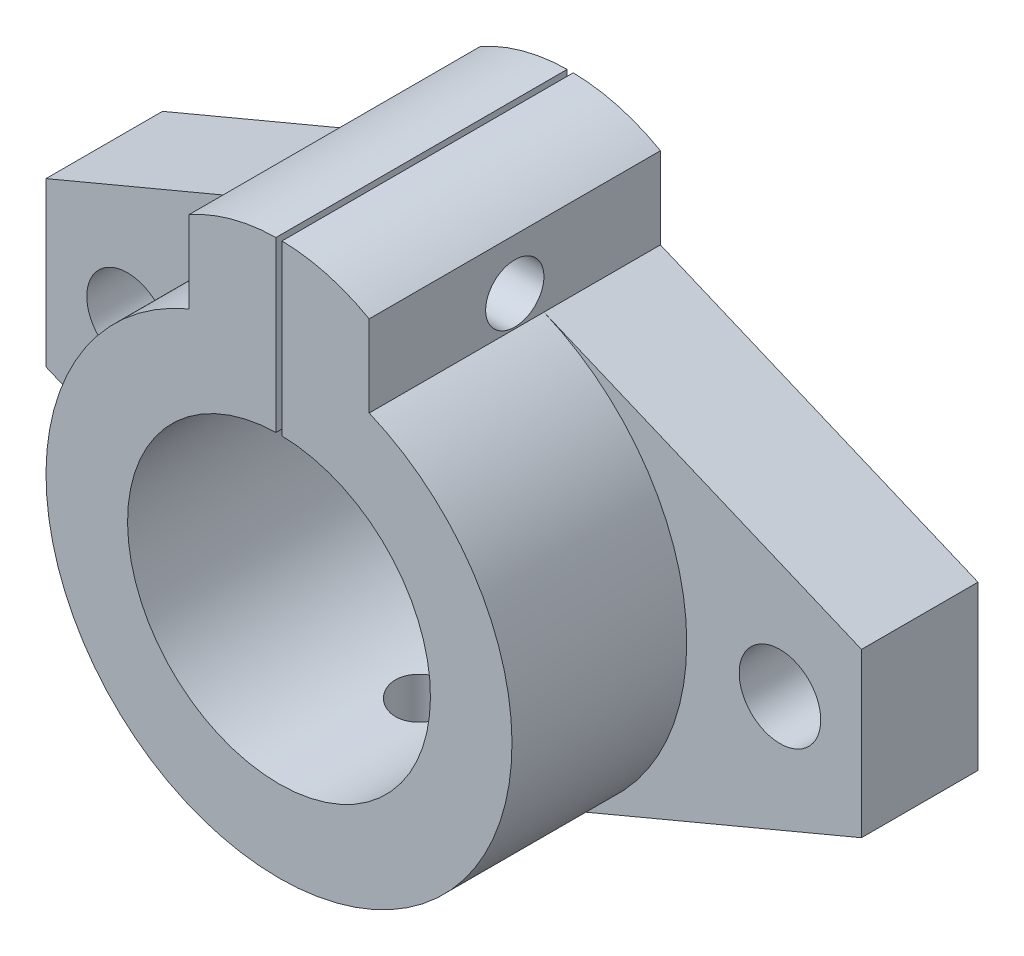
from build123d import *

# Parameters (mm, degrees)
SKETCH_1_R          = 3.5
SKETCH_1_R_2        = 13
EXTRUDE_2_DEPTH     = 10
SKETCH_2_R          = 13
EXTRUDE_3_DEPTH     = 15
SKETCH_3_W          = 0.517195108
SKETCH_3_H          = 18.726193104
CUT_EXTRUDE_1_DEPTH = 26
SKETCH_4_R          = 2.5
CUT_EXTRUDE_2_DEPTH = 43.740275714
SKETCH_5_R          = 2.5
CUT_EXTRUDE_3_DEPTH = 21


with BuildPart() as part:
    # 草图1 → 凸台-拉伸2 (new body)
    with BuildSketch(Plane.XY):
        with BuildLine():
            Line((-35, -7), (-7.740275714, -18.44147857))
            ThreePointArc((-7.740275714, -18.44147857), (0, -20), (7.740275714, -18.44147857))
            Line((7.740275714, -18.44147857), (35, -7))
            Line((35, -7), (35, 7))
            Line((35, 7), (7.740275714, 18.44147857))
            Line((7.740275714, 18.44147857), (7.740275714, 25.44147857))
            ThreePointArc((7.740275714, 25.44147857), (0, 27.494244152), (-7.740275714, 25.44147857))
            Line((-7.740275714, 25.44147857), (-7.740275714, 18.44147857))
            Line((-7.740275714, 18.44147857), (-35, 7))
            Line((-35, 7), (-35, -7))
        make_face()
        with Locations((-28, 0)):
            Circle(SKETCH_1_R, mode=Mode.SUBTRACT)
        Circle(SKETCH_1_R_2, mode=Mode.SUBTRACT)
        with Locations((28, 0)):
            Circle(SKETCH_1_R, mode=Mode.SUBTRACT)
    extrude(amount=EXTRUDE_2_DEPTH)

    # 草图2 → 凸台-拉伸3 (add)
    with BuildSketch(Plane.XY.offset(10)):
        with BuildLine():
            Line((-7.740275714, 18.44147857), (-7.740275714, 25.44147857))
            ThreePointArc((-7.740275714, 25.44147857), (0, 27.494244152), (7.740275714, 25.44147857))
            Line((7.740275714, 25.44147857), (7.740275714, 18.44147857))
            ThreePointArc((7.740275714, 18.44147857), (0, -20), (-7.740275714, 18.44147857))
        make_face()
        Circle(SKETCH_2_R, mode=Mode.SUBTRACT)
    extrude(amount=EXTRUDE_3_DEPTH)

    # 草图3 → 切除-拉伸1 (cut, through all)
    with BuildSketch(Plane.XY.offset(25)):
        with Locations((0, 21.741202931)):
            Rectangle(SKETCH_3_W, SKETCH_3_H)
    extrude(amount=-CUT_EXTRUDE_1_DEPTH, mode=Mode.SUBTRACT)

    # 草图4 → 切除-拉伸2 (cut, through all)
    with BuildSketch(Plane(origin=(7.740275714, 0, 0), x_dir=(0, 0, -1), z_dir=(1, 0, 0))):
        with Locations((-12.5, 21.086423576)):
            Circle(SKETCH_4_R)
    extrude(amount=-CUT_EXTRUDE_2_DEPTH, mode=Mode.SUBTRACT)

    # 草图5 → 切除-拉伸3 (cut, through all)
    with BuildSketch(Plane(origin=(0, 0, 0), x_dir=(1, 0, 0), z_dir=(0, 1, 0))):
        with Locations((0, -12.5)):
            Circle(SKETCH_5_R)
    extrude(amount=-CUT_EXTRUDE_3_DEPTH, mode=Mode.SUBTRACT)


solid = part.part
